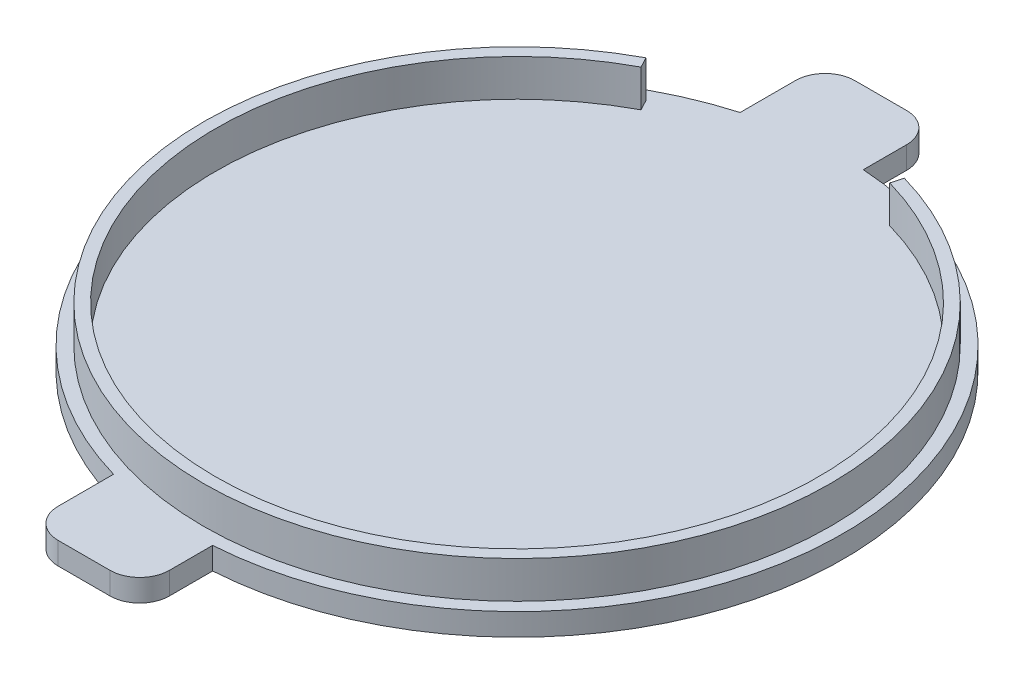
from build123d import *

# Parameters (mm, degrees)
SKETCH1_R           = 44
BOSS_EXTRUDE1_DEPTH = 3
BOSS_EXTRUDE2_DEPTH = 5
BOSS_EXTRUDE3_DEPTH = 3


with BuildPart() as part:
    # Sketch1 → Boss-Extrude1 (new body)
    with BuildSketch(Plane(origin=(0, 0, 0), x_dir=(1, 0, 0), z_dir=(0, 1, 0))):
        Circle(SKETCH1_R)
    extrude(amount=BOSS_EXTRUDE1_DEPTH)

    # Sketch2 → Boss-Extrude2 (add)
    with BuildSketch(Plane(origin=(0, 3, 0), x_dir=(1, 0, 0), z_dir=(0, 1, 0))):
        with BuildLine():
            Line((-19.168383357, 35.903524611), (-19.921931597, 37.314965382))
            ThreePointArc((-19.921931597, 37.314965382), (4.492861264, -42.060720366), (11.590514748, 40.681076287))
            Line((11.590514748, 40.681076287), (11.152102843, 39.142312172))
            ThreePointArc((11.152102843, 39.142312172), (4.322918521, -40.469771132), (-19.168383357, 35.903524611))
        make_face()
    extrude(amount=BOSS_EXTRUDE2_DEPTH)

    # Sketch3 → Boss-Extrude3 (add)
    with BuildSketch(Plane.XZ):
        with BuildLine():
            Line((-1.173425428, -53.751103926), (-8.173425428, -53.751103926))
            ThreePointArc((-8.173425428, -53.751103926), (-11.001852553, -52.579531051), (-12.173425428, -49.751103926))
            Line((-12.173425428, -49.751103926), (-12.173425428, -33.751103926))
            Line((-12.173425428, -33.751103926), (2.826574572, -33.751103926))
            Line((2.826574572, -33.751103926), (2.826574572, -49.751103926))
            ThreePointArc((2.826574572, -49.751103926), (1.655001697, -52.579531051), (-1.173425428, -53.751103926))
        make_face()
    boss_extrude3 = extrude(amount=-BOSS_EXTRUDE3_DEPTH)

    # Mirror1: Boss-Extrude3 across plane
    add(boss_extrude3.mirror(Plane.XY))


solid = part.part
